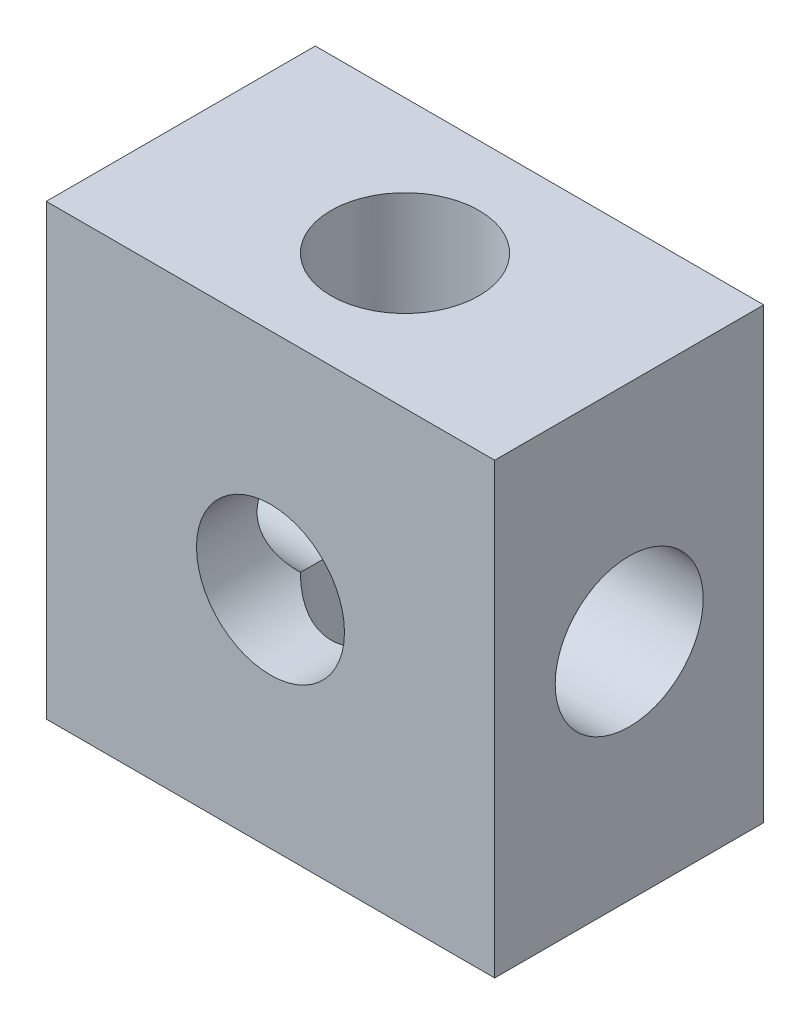
from build123d import *

# Parameters (mm, degrees)
SKETCH_1_W               = 10
SKETCH_1_H               = 10
EXTRUDE_1_DEPTH          = 6
SKETCH_2_R               = 1.65
CUT_EXTRUDE_1_DEPTH      = 6
SKETCH_3_R               = 1.65
CUT_EXTRUDE_2_DEPTH      = 1
CUT_EXTRUDE_2_DEPTH_BACK = 11
SKETCH_4_R               = 1.65
CUT_EXTRUDE_3_DEPTH      = 11


with BuildPart() as part:
    # 草图1 → 凸台-拉伸1 (new body)
    with BuildSketch(Plane.XY):
        Rectangle(SKETCH_1_W, SKETCH_1_H)
    extrude(amount=EXTRUDE_1_DEPTH)

    # 草图2 → 切除-拉伸1 (cut)
    with BuildSketch(Plane.XY.offset(6)):
        Circle(SKETCH_2_R)
    extrude(amount=-CUT_EXTRUDE_1_DEPTH, mode=Mode.SUBTRACT)

    # 草图3 → 切除-拉伸2 (cut, two sides)
    with BuildSketch(Plane.ZY.offset(5)) as cut_extrude_2_sk:
        with Locations((3, 0)):
            Circle(SKETCH_3_R)
    extrude(amount=CUT_EXTRUDE_2_DEPTH, mode=Mode.SUBTRACT)
    extrude(cut_extrude_2_sk.sketch, amount=-CUT_EXTRUDE_2_DEPTH_BACK, mode=Mode.SUBTRACT)

    # 草图4 → 切除-拉伸3 (cut, through all)
    with BuildSketch(Plane(origin=(0, 5, 0), x_dir=(1, 0, 0), z_dir=(0, 1, 0))):
        with Locations((0, -3)):
            Circle(SKETCH_4_R)
    extrude(amount=-CUT_EXTRUDE_3_DEPTH, mode=Mode.SUBTRACT)


solid = part.part
